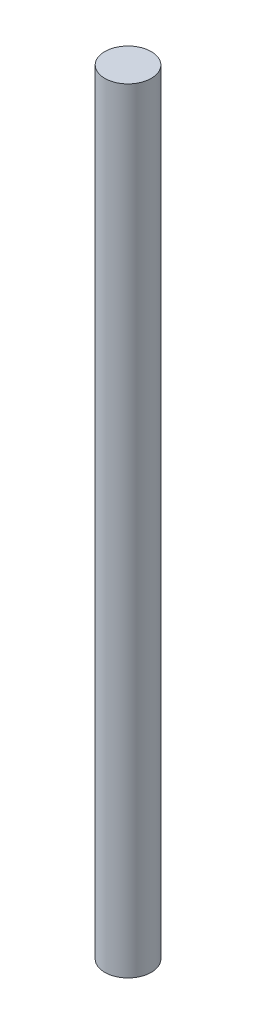
from build123d import *

# Parameters (mm, degrees)
SKETCH1_W = 4.5
SKETCH1_H = 150


with BuildPart() as part:
    # Sketch1 → Revolve1 (revolve)
    with BuildSketch(Plane.XY):
        with Locations((2.25, 75)):
            Rectangle(SKETCH1_W, SKETCH1_H)
    revolve(axis=Axis((0, 0, 0), (0, 1, 0)))


solid = part.part
